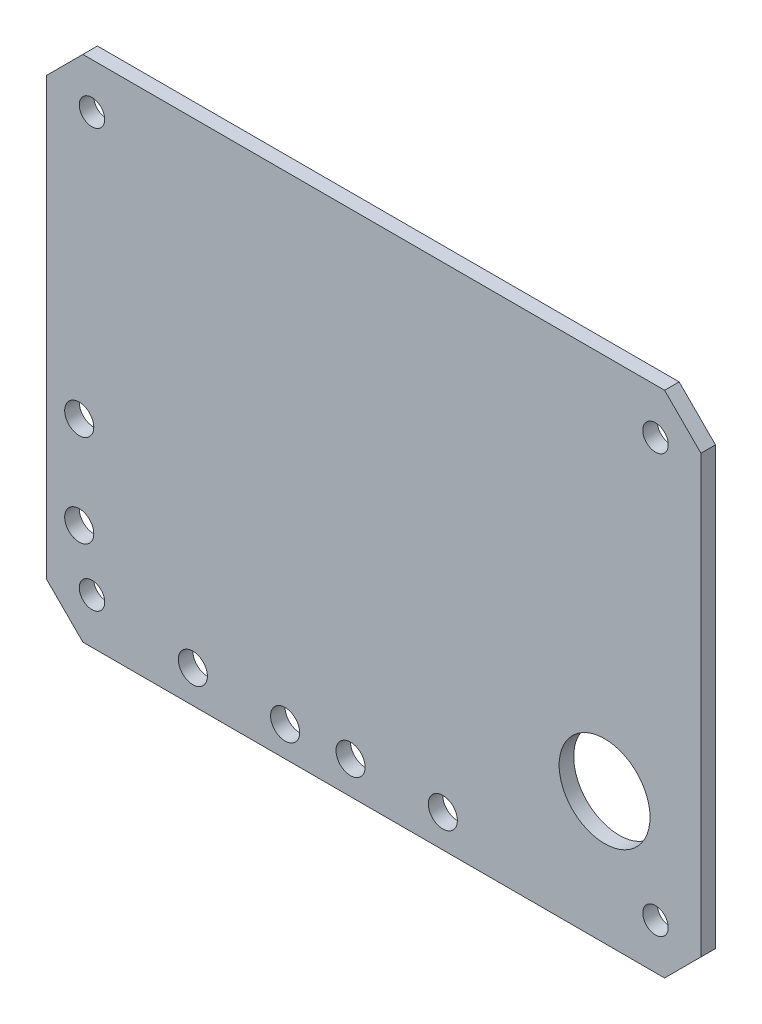
from build123d import *

# Parameters (mm, degrees)
BOSS_EXTRUDE1_DEPTH = 1.6
SKETCH2_R           = 1.4
CUT_EXTRUDE1_DEPTH  = 1.6
SKETCH3_R           = 5
CUT_EXTRUDE2_DEPTH  = 1.6
SKETCH4_R           = 1.6
CUT_EXTRUDE3_DEPTH  = 10


with BuildPart() as part:
    # Sketch1 → Boss-Extrude1 (new body)
    with BuildSketch(Plane.XY):
        Polygon((32, 28), (36, 24), (36, -24), (32, -28), (-32, -28), (-36, -24), (-36, 24), (-32, 28), align=None)
    extrude(amount=BOSS_EXTRUDE1_DEPTH)

    # Sketch2 → Cut-Extrude1 (cut)
    with BuildSketch(Plane.XY.offset(1.6)):
        with Locations((-31, 23)):
            Circle(SKETCH2_R)
        with Locations((31, 23)):
            Circle(SKETCH2_R)
        with Locations((-31, -23)):
            Circle(SKETCH2_R)
        with Locations((31, -23)):
            Circle(SKETCH2_R)
    extrude(amount=-CUT_EXTRUDE1_DEPTH, mode=Mode.SUBTRACT)

    # Sketch3 → Cut-Extrude2 (cut)
    with BuildSketch(Plane.XY.offset(1.6)):
        with Locations((25.4, -13.5)):
            Circle(SKETCH3_R)
    extrude(amount=-CUT_EXTRUDE2_DEPTH, mode=Mode.SUBTRACT)

    # Sketch4 → Cut-Extrude3 (cut)
    with BuildSketch(Plane.XY.offset(1.6)):
        with Locations((-19.9, -24.4)):
            Circle(SKETCH4_R)
        with Locations((-9.75, -24.698906537)):
            Circle(SKETCH4_R)
        with Locations((-2.55, -24.4)):
            Circle(SKETCH4_R)
        with Locations((7.6, -24.4)):
            Circle(SKETCH4_R)
        with Locations((-32.4, -17.075)):
            Circle(SKETCH4_R)
        with Locations((-32.4, -6.925)):
            Circle(SKETCH4_R)
    extrude(amount=-CUT_EXTRUDE3_DEPTH, mode=Mode.SUBTRACT)


solid = part.part
